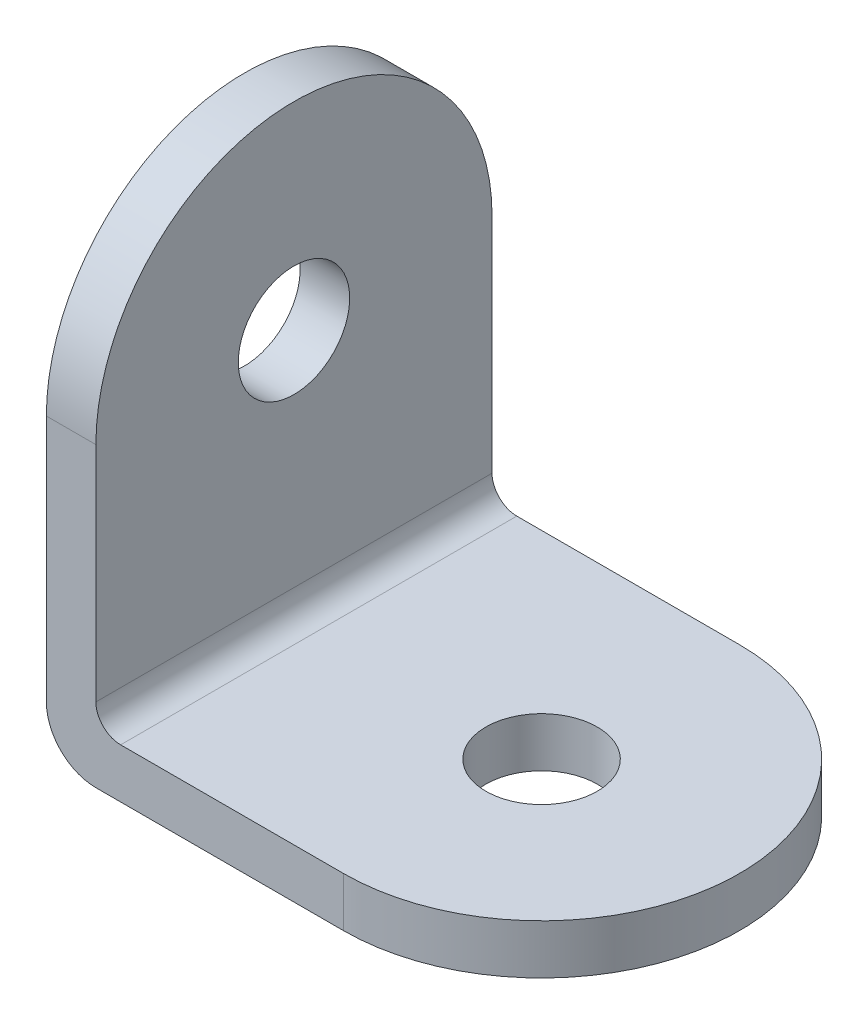
from build123d import *

# Parameters (mm, degrees)
EXTRUDE_1_DEPTH     = 16
CUT_EXTRUDE_1_DEPTH = 21
CUT_EXTRUDE_2_DEPTH = 21
FILLET_1_R          = 1
FILLET_2_R          = 2
SKETCH_4_R          = 2.25
CUT_EXTRUDE_3_DEPTH = 3
SKETCH_5_R          = 2.25
CUT_EXTRUDE_4_DEPTH = 3


with BuildPart() as part:
    # Sketch 1 → Бобышка-Вытянуть1 (new body)
    with BuildSketch(Plane.XY):
        Polygon((0, 0), (0, 20), (2, 20), (2, 2), (20, 2), (20, 0), align=None)
    extrude(amount=EXTRUDE_1_DEPTH)

    # Эскиз2 → Вырез-Вытянуть1 (cut, through all)
    with BuildSketch(Plane.XZ):
        with BuildLine():
            Line((20, 0), (20, 8.000000031))
            ThreePointArc((20, 8.000000031), (17.656854261, 2.343145762), (12, 0))
            Line((12, 0), (20, 0))
        make_face()
        with BuildLine():
            Line((20, 16), (12, 16))
            ThreePointArc((12, 16), (17.656854238, 13.656854261), (20, 8.000000031))
            Line((20, 8.000000031), (20, 16))
        make_face()
    extrude(amount=-CUT_EXTRUDE_1_DEPTH, mode=Mode.SUBTRACT)

    # Эскиз3 → Вырез-Вытянуть2 (cut, through all)
    with BuildSketch(Plane.ZY):
        with BuildLine():
            Line((8, 20), (0, 20))
            Line((0, 20), (0, 12))
            ThreePointArc((0, 12), (2.343145751, 17.656854249), (8, 20))
        make_face()
        with BuildLine():
            Line((16, 20), (8, 20))
            ThreePointArc((8, 20), (13.656854249, 17.656854249), (16, 12))
            Line((16, 12), (16, 20))
        make_face()
    extrude(amount=-CUT_EXTRUDE_2_DEPTH, mode=Mode.SUBTRACT)

    # Скругление1
    fillet_1_edges = [part.edges().sort_by_distance(p)[0] for p in [
        (2, 2, 8),
    ]]
    fillet(fillet_1_edges, radius=FILLET_1_R)

    # Скругление2
    fillet_2_edges = [part.edges().sort_by_distance(p)[0] for p in [
        (0, 0, 8),
    ]]
    fillet(fillet_2_edges, radius=FILLET_2_R)

    # Эскиз4 → Вырез-Вытянуть3 (cut, through all)
    with BuildSketch(Plane(origin=(2, 0, 0), x_dir=(0, 0, -1), z_dir=(1, 0, 0))):
        with Locations((-8, 12)):
            Circle(SKETCH_4_R)
    extrude(amount=-CUT_EXTRUDE_3_DEPTH, mode=Mode.SUBTRACT)

    # Эскиз5 → Вырез-Вытянуть4 (cut, through all)
    with BuildSketch(Plane(origin=(0, 2, 0), x_dir=(1, 0, 0), z_dir=(0, 1, 0))):
        with Locations((12, -8)):
            Circle(SKETCH_5_R)
    extrude(amount=-CUT_EXTRUDE_4_DEPTH, mode=Mode.SUBTRACT)


solid = part.part
